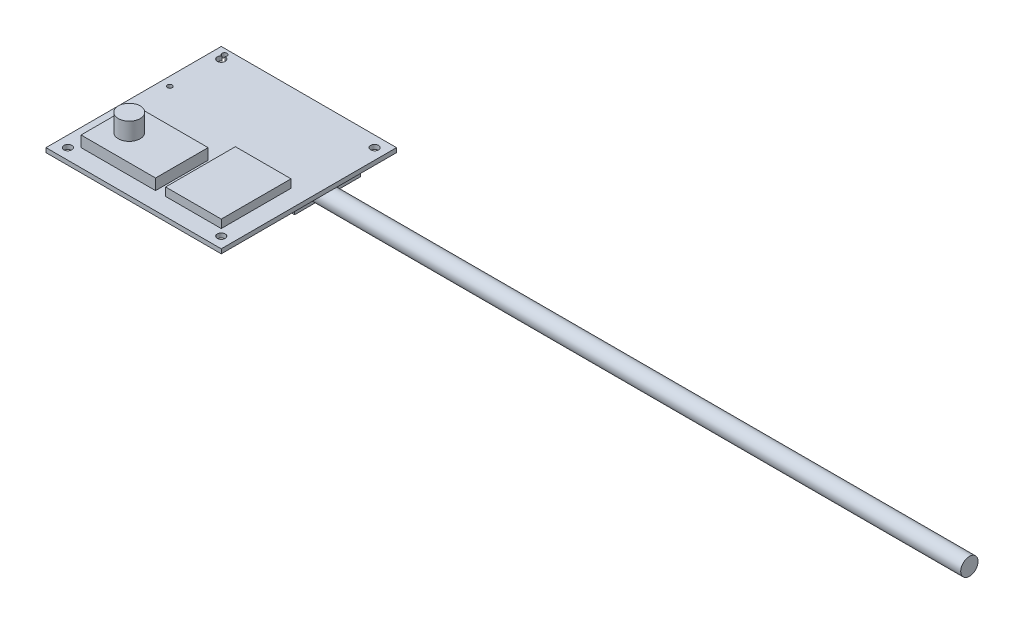
from build123d import *

# Parameters (mm, degrees)
SKETCH1_W                  = 80
SKETCH1_H                  = 80
PCB_DEPTH                  = 2
SKETCH2_R                  = 1.8
ATTACHMENT_HOLES_DEPTH     = 3
LPATTERN1_COUNT            = 2
LPATTERN1_PITCH            = 70
LPATTERN1_COUNT_DIR2       = 2
LPATTERN1_PITCH_DIR2       = 70
SKETCH3_W                  = 57
SKETCH3_H                  = 30
COMMS_CHIP_DEPTH           = 12.8
SKETCH4_R                  = 1.115
COMM_CHIP_ATTACHMENT_DEPTH = 15.8
LPATTERN2_COUNT            = 2
LPATTERN2_PITCH            = 25
SKETCH5_W                  = 34
SKETCH5_H                  = 24
ARDUCAMMINI_DEPTH          = 5
SKETCH8_R                  = 5
LENS_APPROXIMATE_DEPTH     = 8
SKETCH6_W                  = 25.4
SKETCH6_H                  = 31.85
SD_CARD_DEPTH              = 3.75
SKETCH7_R                  = 3.95
ANTENNA_DEPTH              = 300


with BuildPart() as part:
    # Sketch1 → PCB (new body)
    with BuildSketch(Plane(origin=(0, 0, 0), x_dir=(1, 0, 0), z_dir=(0, 1, 0))):
        with Locations((40, 40)):
            Rectangle(SKETCH1_W, SKETCH1_H)
    extrude(amount=PCB_DEPTH)

    # Sketch2 → Attachment Holes (cut, through all)
    with BuildSketch(Plane(origin=(0, 2, 0), x_dir=(1, 0, 0), z_dir=(0, 1, 0))):
        with Locations((5, 75)):
            Circle(SKETCH2_R)
    attachment_holes = extrude(amount=-ATTACHMENT_HOLES_DEPTH, mode=Mode.SUBTRACT)

    # LPattern1: Attachment Holes 2 × 2
    with Locations(*[(i * LPATTERN1_PITCH, 0, j * LPATTERN1_PITCH_DIR2) for i in range(LPATTERN1_COUNT) for j in range(LPATTERN1_COUNT_DIR2) if (i, j) != (0, 0)]):
        add(attachment_holes, mode=Mode.SUBTRACT)

    # Sketch3 → Comms Chip (add)
    with BuildSketch(Plane(origin=(0, 0, 0), x_dir=(1, 0, 0), z_dir=(0, 1, 0))):
        with Locations((40, 60)):
            Rectangle(SKETCH3_W, SKETCH3_H)
    extrude(amount=-COMMS_CHIP_DEPTH)

    # Sketch4 → Comm chip attachment (cut, through all)
    with BuildSketch(Plane(origin=(0, -12.8, 0), x_dir=(-1, 0, 0), z_dir=(0, -1, 0))):
        with Locations((-4, 77.5)):
            Circle(SKETCH4_R)
    comm_chip_attachment = extrude(amount=-COMM_CHIP_ATTACHMENT_DEPTH, mode=Mode.SUBTRACT)

    # LPattern2: Comm chip attachment ×2
    with Locations(*[(0, 0, i * LPATTERN2_PITCH) for i in range(1, LPATTERN2_COUNT)]):
        add(comm_chip_attachment, mode=Mode.SUBTRACT)

    # Sketch5 → ArducamMini (add)
    with BuildSketch(Plane(origin=(0, 2, 0), x_dir=(1, 0, 0), z_dir=(0, 1, 0))):
        with Locations((25, 20)):
            Rectangle(SKETCH5_W, SKETCH5_H)
    extrude(amount=ARDUCAMMINI_DEPTH)

    # Sketch8 → Lens, approximate (add)
    with BuildSketch(Plane(origin=(0, 7, 0), x_dir=(1, 0, 0), z_dir=(0, 1, 0))):
        with Locations((18, 20)):
            Circle(SKETCH8_R)
    extrude(amount=LENS_APPROXIMATE_DEPTH)

    # Sketch6 → SD Card (add)
    with BuildSketch(Plane(origin=(0, 2, 0), x_dir=(1, 0, 0), z_dir=(0, 1, 0))):
        with Locations((59.3, 23.925)):
            Rectangle(SKETCH6_W, SKETCH6_H)
    extrude(amount=SD_CARD_DEPTH)

    # Sketch7 → Antenna (add)
    with BuildSketch(Plane(origin=(68.5, -53.7, 0), x_dir=(0, 1, 0), z_dir=(-1, 0, 0))):
        with Locations((47.9, 53)):
            Circle(SKETCH7_R)
    extrude(amount=-ANTENNA_DEPTH)


solid = part.part
